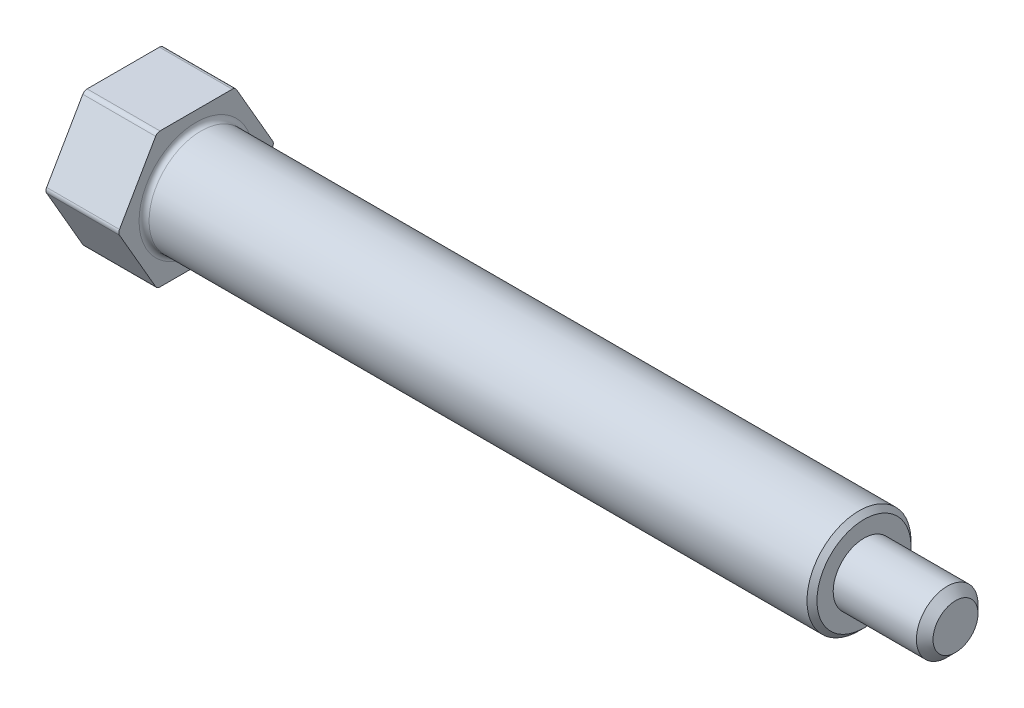
from build123d import *

# Parameters (mm, degrees)
CHAMFER1_SIZE  = 1.27
SKETCH2_R      = 7.9375
EXTRUDE1_DEPTH = 11.1125
FILLET1_R      = 0.762
CHAMFER2_SIZE  = 0.762
FILLET2_R      = 0.762


with BuildPart() as part:
    # Sketch1 → Revolve1 (revolve)
    with BuildSketch(Plane.XY, mode=Mode.PRIVATE) as revolve1_sk:
        Polygon((127, 0), (127, 4.699), (113.03, 4.699), (113.03, 7.9375), (0, 7.9375), (0, 0), align=None)
    revolve(revolve1_sk.sketch.rotate(Axis((-72.566001994, 0, 0), (1, 0, 0)), 90), axis=Axis((-72.566001994, 0, 0), (1, 0, 0)))  # turned: the seam where the file's is

    # Chamfer1
    chamfer1_edges = [part.edges().sort_by_distance(p)[0] for p in [
        (127, 0, -4.699),
    ]]
    chamfer(chamfer1_edges, length=CHAMFER1_SIZE)

    # Sketch2 → Extrude1 (add)
    with BuildSketch(Plane.ZY):
        Polygon((5.953866916, -10.3124), (11.907733832, 0), (5.953866916, 10.3124), (-5.953866916, 10.3124), (-11.907733832, 0), (-5.953866916, -10.3124), align=None)
        Circle(SKETCH2_R, mode=Mode.SUBTRACT)
    extrude(amount=-EXTRUDE1_DEPTH)

    # Fillet1
    fillet1_edges = [part.edges().sort_by_distance(p)[0] for p in [
        (5.55625, -10.3124, 5.953866916),
        (5.55625, -10.3124, -5.953866916),
        (5.55625, 0, -11.907733832),
        (5.55625, 10.3124, -5.953866916),
        (5.55625, 10.3124, 5.953866916),
        (5.55625, 0, 11.907733832),
    ]]
    fillet(fillet1_edges, radius=FILLET1_R)

    # Chamfer2
    chamfer2_edges = [part.edges().sort_by_distance(p)[0] for p in [
        (113.03, 0, -7.9375),
    ]]
    chamfer(chamfer2_edges, length=CHAMFER2_SIZE)

    # Fillet2
    fillet2_edges = [part.edges().sort_by_distance(p)[0] for p in [
        (11.1125, 0, -7.9375),
    ]]
    fillet(fillet2_edges, radius=FILLET2_R)


solid = part.part
